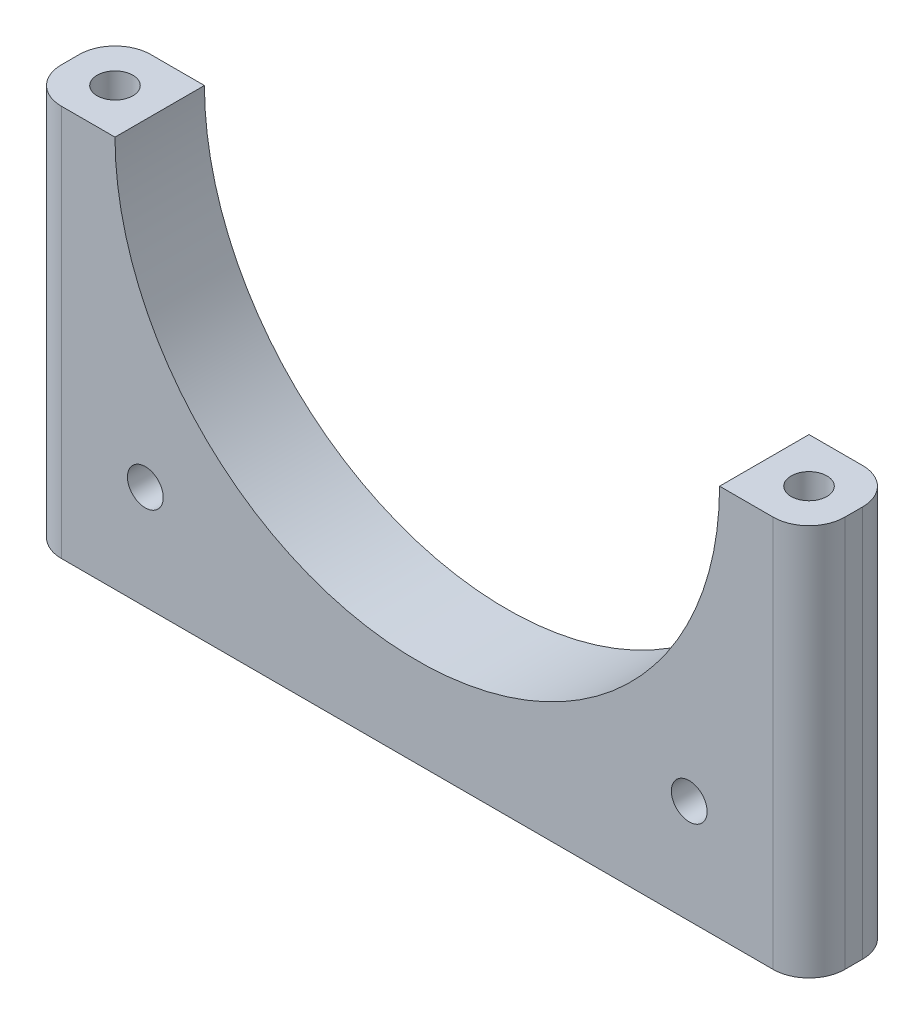
from build123d import *

# Parameters (mm, degrees)
BOSS_EXTRUDE1_DEPTH = 25
SKETCH5_R           = 5
CUT_EXTRUDE1_DEPTH  = 5000
SKETCH6_R           = 5
CUT_EXTRUDE2_DEPTH  = 5000
FILLET2_R           = 10


with BuildPart() as part:
    # Sketch4 → Boss-Extrude1 (new body)
    with BuildSketch(Plane.XY):
        with BuildLine():
            ThreePointArc((0, -25), (-77.42819254, 7.07180746), (-109.5, 84.5))
            Line((-109.5, 84.5), (-109.5, -25))
            Line((-109.5, -25), (0, -25))
        make_face()
        with BuildLine():
            ThreePointArc((84.5, 84.5), (59.75052301, 24.74947699), (0, 0))
            ThreePointArc((0, 0), (-59.75052301, 24.74947699), (-84.5, 84.5))
            Line((-84.5, 84.5), (-109.5, 84.5))
            ThreePointArc((-109.5, 84.5), (-77.42819254, 7.07180746), (0, -25))
            ThreePointArc((0, -25), (77.42819254, 7.07180746), (109.5, 84.5))
            Line((109.5, 84.5), (84.5, 84.5))
        make_face()
        with BuildLine():
            Line((109.5, -25), (109.5, 84.5))
            ThreePointArc((109.5, 84.5), (77.42819254, 7.07180746), (0, -25))
            Line((0, -25), (109.5, -25))
        make_face()
    extrude(amount=BOSS_EXTRUDE1_DEPTH)

    # Sketch5 → Cut-Extrude1 (cut)
    with BuildSketch(Plane(origin=(0, 84.5, 0), x_dir=(1, 0, 0), z_dir=(0, 1, 0))):
        with Locations((-97, -12.5)):
            Circle(SKETCH5_R)
        with Locations((97, -12.5)):
            Circle(SKETCH5_R)
    extrude(amount=-CUT_EXTRUDE1_DEPTH, mode=Mode.SUBTRACT)

    # Sketch6 → Cut-Extrude2 (cut)
    with BuildSketch(Plane.XY.offset(25)):
        with Locations((-76.015, 3.99)):
            Circle(SKETCH6_R)
        with Locations((76.015, 3.99)):
            Circle(SKETCH6_R)
    extrude(amount=-CUT_EXTRUDE2_DEPTH, mode=Mode.SUBTRACT)

    # Fillet2
    fillet2_edges = [part.edges().sort_by_distance(p)[0] for p in [
        (109.5, 29.75, 25),
        (-109.5, 29.75, 25),
        (-109.5, 29.75, 0),
        (109.5, 29.75, 0),
    ]]
    fillet(fillet2_edges, radius=FILLET2_R)


solid = part.part
